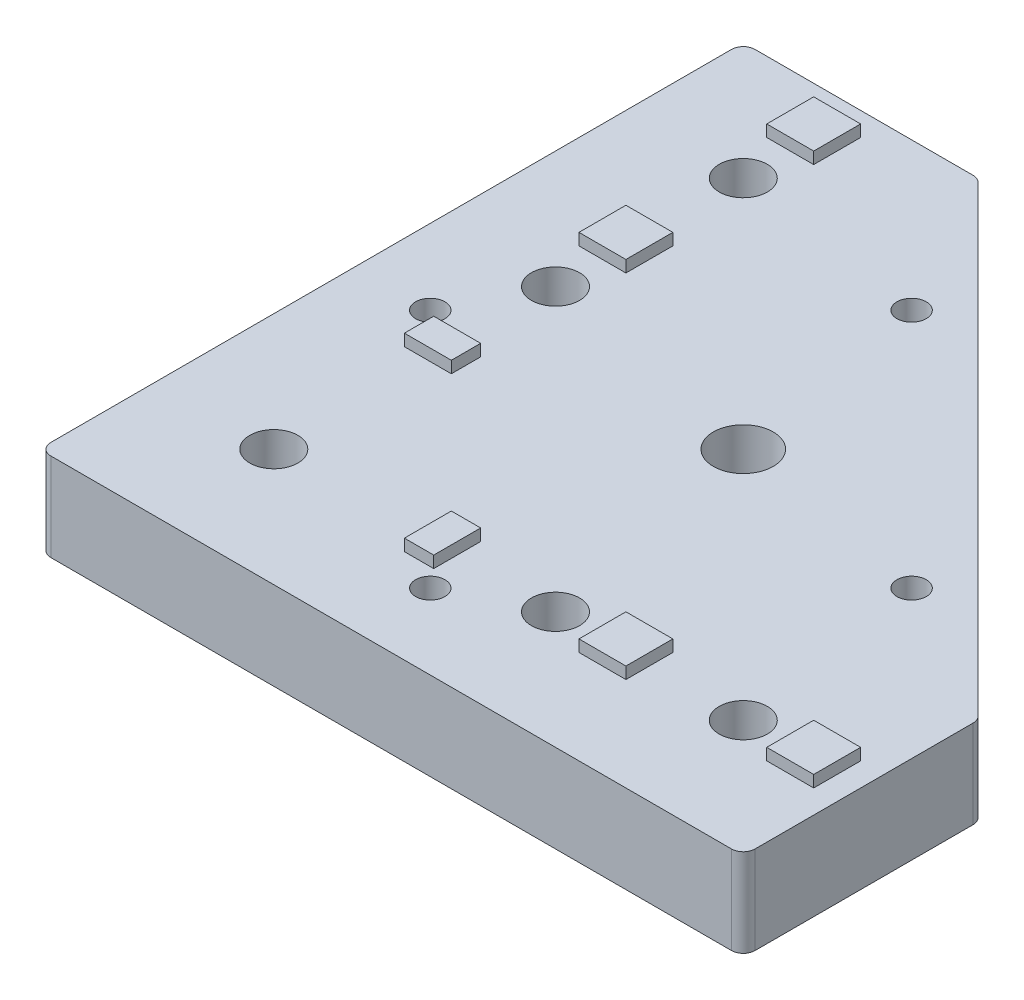
from build123d import *

# Parameters (mm, degrees)
EXTRUDE_1_DEPTH             = 15
HOLE_WIZARD_M121_D          = 10.2
HOLE_WIZARD_M121_DEPTH      = 15
HOLE_WIZARD_M62_D           = 5
HOLE_WIZARD_M62_DEPTH       = 15
HOLE_WIZARD_8_2_8_2_1_D     = 8.2
HOLE_WIZARD_8_2_8_2_1_DEPTH = 15
SKETCH_9_W                  = 8
SKETCH_9_H                  = 8
SKETCH_9_H_2                = 5
SKETCH_9_W_2                = 5
EXTRUDE_2_DEPTH             = 2
FILLET_1_R                  = 2


with BuildPart() as part:
    # Эскиз1 → Бобышка-Вытянуть1 (new body)
    with BuildSketch(Plane(origin=(0, 0, 0), x_dir=(1, 0, 0), z_dir=(0, 1, 0))):
        Polygon((0, 0), (0, 120), (40, 120), (120, 40), (120, 0), align=None)
    extrude(amount=EXTRUDE_1_DEPTH)

    # Отверстие обработанное метчиком M121
    with Locations(Plane(origin=(0, 15, 0), x_dir=(1, 0, 0), z_dir=(0, 1, 0))):
        with Locations((60, 60)):
            Hole(HOLE_WIZARD_M121_D / 2, depth=HOLE_WIZARD_M121_DEPTH)

    # Отверстие обработанное метчиком M62
    with Locations(Plane(origin=(0, 15, 0), x_dir=(1, 0, 0), z_dir=(0, 1, 0))):
        with Locations((53.837049096, 94.849242405), (94.849242405, 53.837049096), (53.837049096, 12.824855787), (12.824855787, 53.837049096)):
            Hole(HOLE_WIZARD_M62_D / 2, depth=HOLE_WIZARD_M62_DEPTH)

    # Диаметр отверстия Ø8.2 (8.2)1
    with Locations(Plane(origin=(0, 15, 0), x_dir=(1, 0, 0), z_dir=(0, 1, 0))):
        with Locations((20, 100), (20, 68), (20, 20), (68, 20), (100, 20)):
            Hole(HOLE_WIZARD_8_2_8_2_1_D / 2, depth=HOLE_WIZARD_8_2_8_2_1_DEPTH)

    # Эскиз9 → Бобышка-Вытянуть2 (add)
    with BuildSketch(Plane(origin=(0, 15, 0), x_dir=(1, 0, 0), z_dir=(0, 1, 0))):
        with Locations((20, 112)):
            Rectangle(SKETCH_9_W, SKETCH_9_H)
        with Locations((20, 80)):
            Rectangle(SKETCH_9_W, SKETCH_9_H)
        with Locations((20, 48.75)):
            Rectangle(SKETCH_9_W, SKETCH_9_H_2)
        with Locations((48.75, 20)):
            Rectangle(SKETCH_9_W_2, SKETCH_9_H)
        with Locations((80, 20)):
            Rectangle(SKETCH_9_W, SKETCH_9_H)
        with Locations((112, 20)):
            Rectangle(SKETCH_9_W, SKETCH_9_H)
    extrude(amount=EXTRUDE_2_DEPTH)

    # Скругление1
    fillet_1_edges = [part.edges().sort_by_distance(p)[0] for p in [
        (0, 7.5, 0),
        (0, 7.5, -120),
        (40, 7.5, -120),
        (120, 7.5, -40),
        (120, 7.5, 0),
    ]]
    fillet(fillet_1_edges, radius=FILLET_1_R)


solid = part.part
